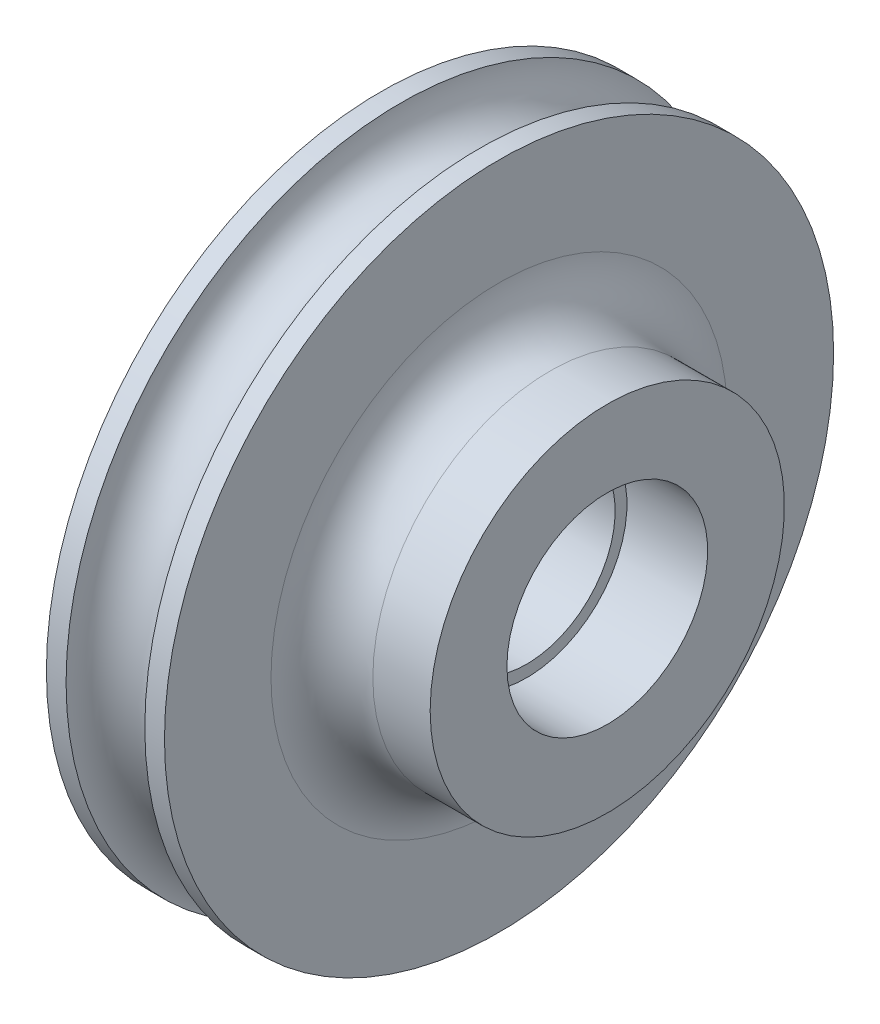
from build123d import *


with BuildPart() as part:
    # 草图1 → 旋转1 (revolve)
    with BuildSketch(Plane.XY):
        with BuildLine():
            Line((2, 17), (3, 17))
            Line((3, 17), (3, 11.587964483))
            ThreePointArc((3, 11.587964483), (3.757997248, 9.757997248), (5.587964483, 9))
            Line((5.587964483, 9), (8.5, 9))
            Line((8.5, 9), (8.5, 5.1))
            Line((8.5, 5.1), (4.4, 5.1))
            Line((4.4, 5.1), (4.4, 4.5))
            Line((4.4, 4.5), (1.1, 4.5))
            Line((1.1, 4.5), (1.1, 5.1))
            Line((1.1, 5.1), (-3, 5.1))
            Line((-3, 5.1), (-3, 17))
            Line((-3, 17), (-2, 17))
            ThreePointArc((-2, 17), (0, 15), (2, 17))
        make_face()
    revolve(axis=Axis((0, 0, 0), (1, 0, 0)))


solid = part.part
